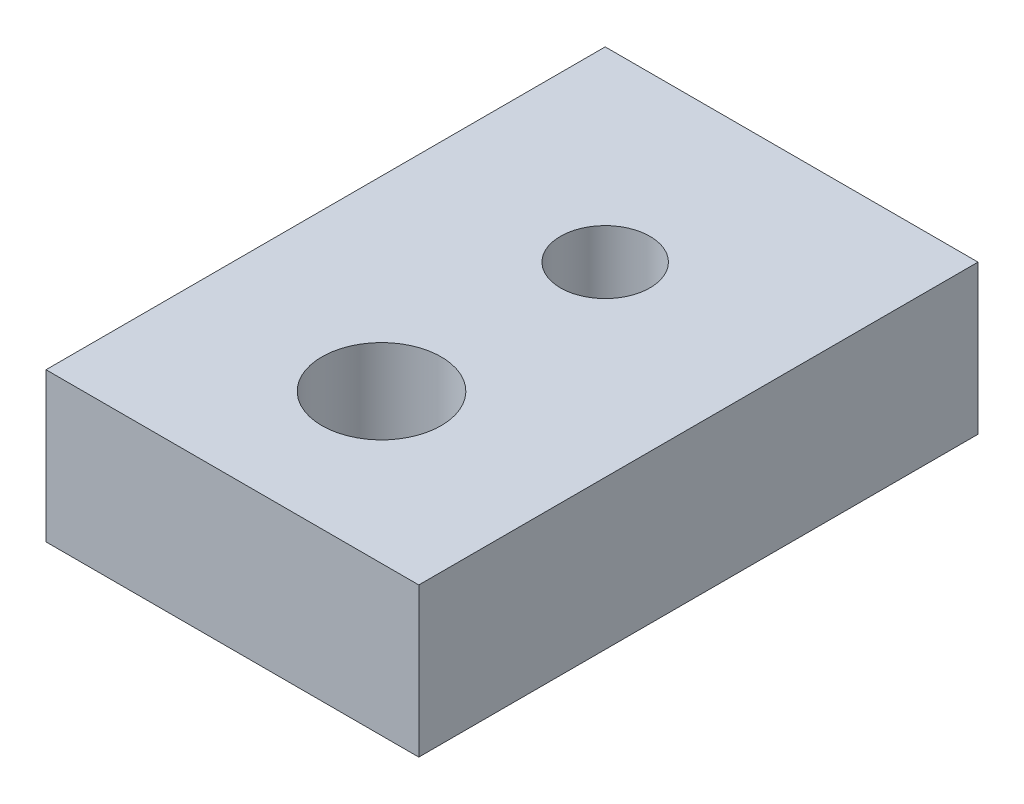
from build123d import *

# Parameters (mm, degrees)
SKETCH1_W           = 50
SKETCH1_H           = 75
SKETCH1_R           = 6
SKETCH1_R_2         = 8
BOSS_EXTRUDE1_DEPTH = 20


with BuildPart() as part:
    # Sketch1 → Boss-Extrude1 (new body)
    with BuildSketch(Plane(origin=(0, 0, 0), x_dir=(1, 0, 0), z_dir=(0, 1, 0))):
        with Locations((0, -12.5)):
            Rectangle(SKETCH1_W, SKETCH1_H)
        Circle(SKETCH1_R, mode=Mode.SUBTRACT)
        with Locations((0, -30)):
            Circle(SKETCH1_R_2, mode=Mode.SUBTRACT)
    extrude(amount=BOSS_EXTRUDE1_DEPTH)


solid = part.part
